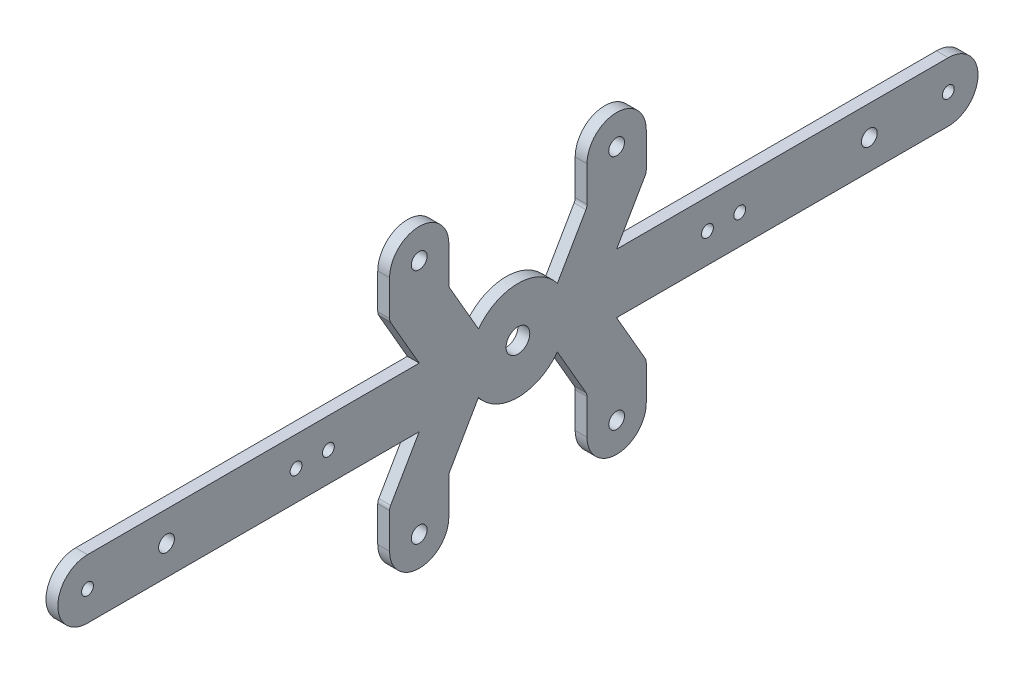
from build123d import *

# Parameters (mm, degrees)
SKETCH1_W               = 250
SKETCH1_H               = 90
BOSS_EXTRUDE1_DEPTH     = 3
SKETCH2_R               = 3
SKETCH2_R_2             = 1.5
SKETCH2_R_3             = 2
CUT_EXTRUDE1_DEPTH      = 4
SKETCH3_R               = 2
CUT_EXTRUDE2_DEPTH      = 4
CUT_EXTRUDE3_DEPTH      = 4
MIRROR2_COPY_1_SKETCH_R = 2
MIRROR2_COPY_1_DEPTH    = 4
MIRROR2_COPY_2_DEPTH    = 4
FILLET2_R               = 2


with BuildPart() as part:
    # Sketch1 → Boss-Extrude1 (new body)
    with BuildSketch(Plane(origin=(0, 0, 0), x_dir=(0, 0, -1), z_dir=(1, 0, 0))):
        Rectangle(SKETCH1_W, SKETCH1_H)
    extrude(amount=BOSS_EXTRUDE1_DEPTH)

    # Sketch2 → Cut-Extrude1 (cut, through all)
    with BuildSketch(Plane(origin=(3, 0, 0), x_dir=(0, 0, -1), z_dir=(1, 0, 0))):
        Circle(SKETCH2_R)
        with Locations((-48, 0)):
            Circle(SKETCH2_R_2)
        with Locations((-89, 0)):
            Circle(SKETCH2_R_3)
        with Locations((-109, 0)):
            Circle(SKETCH2_R_2)
        with Locations((-56.18, 0)):
            Circle(SKETCH2_R_2)
    cut_extrude1 = extrude(amount=-CUT_EXTRUDE1_DEPTH, mode=Mode.SUBTRACT)

    # Sketch3 → Cut-Extrude2 (cut, through all)
    with BuildSketch(Plane(origin=(3, 0, 0), x_dir=(0, 0, -1), z_dir=(1, 0, 0))):
        with Locations((-25, 30)):
            Circle(SKETCH3_R)
    cut_extrude2 = extrude(amount=-CUT_EXTRUDE2_DEPTH, mode=Mode.SUBTRACT)

    # Sketch4 → Cut-Extrude3 (cut, through all)
    with BuildSketch(Plane(origin=(3, 0, 0), x_dir=(0, 0, -1), z_dir=(1, 0, 0))):
        with BuildLine():
            Line((-125, 1.99556796), (-125, 45))
            Line((-125, 45), (0, 45))
            Line((0, 45), (0, 12.5))
            ThreePointArc((0, 12.5), (-5.582012149, 11.184415066), (-9.989046524, 7.514582459))
            Line((-9.989046524, 7.514582459), (-17.5, 20.523935493))
            Line((-17.5, 20.523935493), (-17.5, 30))
            ThreePointArc((-17.5, 30), (-25, 37.5), (-32.5, 30))
            Line((-32.5, 30), (-32.5, 20.523935493))
            Line((-32.5, 20.523935493), (-24.989046524, 7.514582459))
            Line((-24.989046524, 7.514582459), (-109, 7.514582459))
            ThreePointArc((-109, 7.514582459), (-114.313612215, 5.313612215), (-116.514582459, 0))
            Line((-116.514582459, 0), (-125, 0))
            Line((-125, 0), (-125, 1.99556796))
        make_face()
    cut_extrude3 = extrude(amount=-CUT_EXTRUDE3_DEPTH, mode=Mode.SUBTRACT)

    # Mirror1: Cut-Extrude2, Cut-Extrude3 across plane
    add(cut_extrude2.mirror(Plane.ZX), mode=Mode.SUBTRACT)
    add(cut_extrude3.mirror(Plane.ZX), mode=Mode.SUBTRACT)

    # Mirror2: Cut-Extrude1, Cut-Extrude2, Cut-Extrude3 across plane
    add(cut_extrude1.mirror(Plane.XY), mode=Mode.SUBTRACT)
    add(cut_extrude2.mirror(Plane.XY), mode=Mode.SUBTRACT)
    add(cut_extrude3.mirror(Plane.XY), mode=Mode.SUBTRACT)

    # Mirror2 copy 1 sketch → Mirror2 copy 1 (cut, through all)
    with BuildSketch(Plane(origin=(3, 0, 0), x_dir=(0, 0, 1), z_dir=(1, 0, 0))):
        with Locations((-25, 30)):
            Circle(MIRROR2_COPY_1_SKETCH_R)
    extrude(amount=-MIRROR2_COPY_1_DEPTH, mode=Mode.SUBTRACT)

    # Mirror2 copy 2 sketch → Mirror2 copy 2 (cut, through all)
    with BuildSketch(Plane(origin=(3, 0, 0), x_dir=(0, 0, 1), z_dir=(1, 0, 0))):
        with BuildLine():
            Line((-125, 1.99556796), (-125, 45))
            Line((-125, 45), (0, 45))
            Line((0, 45), (0, 12.5))
            ThreePointArc((0, 12.5), (-5.582012149, 11.184415066), (-9.989046524, 7.514582459))
            Line((-9.989046524, 7.514582459), (-17.5, 20.523935493))
            Line((-17.5, 20.523935493), (-17.5, 30))
            ThreePointArc((-17.5, 30), (-25, 37.5), (-32.5, 30))
            Line((-32.5, 30), (-32.5, 20.523935493))
            Line((-32.5, 20.523935493), (-24.989046524, 7.514582459))
            Line((-24.989046524, 7.514582459), (-109, 7.514582459))
            ThreePointArc((-109, 7.514582459), (-114.313612215, 5.313612215), (-116.514582459, 0))
            Line((-116.514582459, 0), (-125, 0))
            Line((-125, 0), (-125, 1.99556796))
        make_face()
    extrude(amount=-MIRROR2_COPY_2_DEPTH, mode=Mode.SUBTRACT)

    # Fillet2
    fillet2_edges = [part.edges().sort_by_distance(p)[0] for p in [
        (1.5, -20.523935493, -32.5),
        (1.5, -20.523935493, -17.5),
        (1.5, 20.523935493, -17.5),
        (1.5, 20.523935493, -32.5),
        (1.5, 20.523935493, 32.5),
        (1.5, 20.523935493, 17.5),
        (1.5, -20.523935493, 17.5),
        (1.5, -20.523935493, 32.5),
    ]]
    fillet(fillet2_edges, radius=FILLET2_R)


solid = part.part
